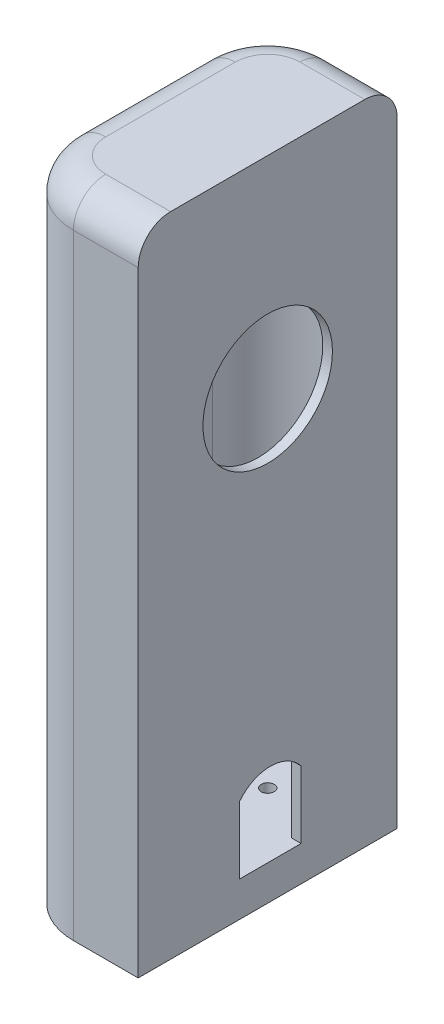
from build123d import *

# Parameters (mm, degrees)
BOSS_EXTRUDE1_DEPTH = 100
SKETCH2_R           = 10
CUT_EXTRUDE1_DEPTH  = 7.5
CUT_EXTRUDE2_DEPTH  = 4.75
SKETCH6_R           = 1
CUT_EXTRUDE3_DEPTH  = 6
SKETCH7_W           = 9.5
SKETCH7_H           = 7.367856256
CUT_EXTRUDE4_DEPTH  = 6
SKETCH8_W           = 9.5
SKETCH8_H           = 7.367856256
BOSS_EXTRUDE2_DEPTH = 12.5
SKETCH10_R          = 10
CUT_EXTRUDE5_DEPTH  = 68
FILLET1_R           = 5
CUT_EXTRUDE6_DEPTH  = 5
SKETCH13_W          = 9.5
SKETCH13_H          = 3
CUT_EXTRUDE7_DEPTH  = 5
CUT_EXTRUDE8_DEPTH  = 12.5
CUT_EXTRUDE9_DEPTH  = 5
SKETCH17_W          = 11
SKETCH17_H          = 9.5
CUT_EXTRUDE11_DEPTH = 90


with BuildPart() as part:
    # Sketch1 → Boss-Extrude1 (new body)
    with BuildSketch(Plane(origin=(0, 0, 0), x_dir=(1, 0, 0), z_dir=(0, 1, 0))):
        with BuildLine():
            Line((-4.0452326, 19.590813971), (5.9547674, 19.590813971))
            Line((5.9547674, 19.590813971), (5.9547674, -0.409186029))
            Line((5.9547674, -0.409186029), (5.9547674, -20.409186029))
            Line((5.9547674, -20.409186029), (-4.0452326, -20.409186029))
            ThreePointArc((-4.0452326, -20.409186029), (-11.116300412, -17.48025384), (-14.0452326, -10.409186029))
            Line((-14.0452326, -10.409186029), (-14.0452326, 9.590813971))
            ThreePointArc((-14.0452326, 9.590813971), (-11.116300412, 16.661881783), (-4.0452326, 19.590813971))
        make_face()
    extrude(amount=BOSS_EXTRUDE1_DEPTH)

    # Sketch2 → Cut-Extrude1 (cut)
    with BuildSketch(Plane(origin=(5.9547674, 0, 0), x_dir=(0, 0, -1), z_dir=(1, 0, 0))):
        with Locations((-0.409186029, 68.83)):
            Circle(SKETCH2_R)
    extrude(amount=-CUT_EXTRUDE1_DEPTH, mode=Mode.SUBTRACT)

    # Sketch4 → Cut-Extrude2 (cut, symmetric)
    with BuildSketch(Plane.XY):
        Polygon((-1.5452326, 89.777572113), (3.4547674, 89.777572113), (3.4547674, 12.777572113), (3.4547674, 5.409715857), (-15.452876316, 5.409715857), (-15.452876316, 12.777572113), (-1.5452326, 12.777572113), align=None)
    extrude(amount=CUT_EXTRUDE2_DEPTH, both=True, mode=Mode.SUBTRACT)

    # Sketch6 → Cut-Extrude3 (cut)
    with BuildSketch(Plane.XZ):
        with Locations((-4.0452326, -9.590813971)):
            Circle(SKETCH6_R)
        with Locations((-4.0452326, 10.409186029)):
            Circle(SKETCH6_R)
    extrude(amount=-CUT_EXTRUDE3_DEPTH, mode=Mode.SUBTRACT)

    # Sketch7 → Cut-Extrude4 (cut)
    with BuildSketch(Plane.ZY.offset(-3.4547674)):
        with Locations((0, 9.093643985)):
            Rectangle(SKETCH7_W, SKETCH7_H)
    extrude(amount=-CUT_EXTRUDE4_DEPTH, mode=Mode.SUBTRACT)

    # Sketch8 → Boss-Extrude2 (add)
    with BuildSketch(Plane.ZY.offset(14.0452326)):
        with Locations((0, 9.093643985)):
            Rectangle(SKETCH8_W, SKETCH8_H)
    extrude(amount=-BOSS_EXTRUDE2_DEPTH)

    # Sketch10 → Cut-Extrude5 (cut)
    with BuildSketch(Plane(origin=(5.9547674, 0, 0), x_dir=(0, 0, -1), z_dir=(1, 0, 0))):
        with Locations((-0.409186029, 68.83)):
            Circle(SKETCH10_R)
    extrude(amount=-CUT_EXTRUDE5_DEPTH, mode=Mode.SUBTRACT)

    # Fillet1
    fillet1_edges = [part.edges().sort_by_distance(p)[0] for p in [
        (-11.116300412, 100, -16.661881783),
        (-14.0452326, 100, 0.409186029),
        (-11.116300412, 100, 17.48025384),
        (0.9547674, 100, 20.409186029),
        (0.9547674, 100, -19.590813971),
    ]]
    fillet(fillet1_edges, radius=FILLET1_R)

    # Sketch11 → Cut-Extrude6 (cut)
    with BuildSketch(Plane(origin=(-1.5452326, 0, 0), x_dir=(0, 0, -1), z_dir=(1, 0, 0))):
        with BuildLine():
            Line((-4.75, 59.821263459), (-4.75, 5.409715857))
            Line((-4.75, 5.409715857), (4.75, 5.409715857))
            Line((4.75, 5.409715857), (4.75, 60.263623898))
            ThreePointArc((4.75, 60.263623898), (0.055952548, 58.840823552), (-4.75, 59.821263459))
        make_face()
    extrude(amount=-CUT_EXTRUDE6_DEPTH, mode=Mode.SUBTRACT)

    # Sketch13 → Cut-Extrude7 (cut)
    with BuildSketch(Plane(origin=(5.9547674, 0, 0), x_dir=(0, 0, -1), z_dir=(1, 0, 0))):
        with Locations((0, 14.277572113)):
            Rectangle(SKETCH13_W, SKETCH13_H)
    extrude(amount=-CUT_EXTRUDE7_DEPTH, mode=Mode.SUBTRACT)

    # Sketch14 → Cut-Extrude8 (cut)
    with BuildSketch(Plane(origin=(5.9547674, 0, 0), x_dir=(0, 0, -1), z_dir=(1, 0, 0))):
        with BuildLine():
            Line((4.75, 15.777572113), (-4.75, 15.777572113))
            ThreePointArc((-4.75, 15.777572113), (0, 18.113561026), (4.75, 15.777572113))
        make_face()
    extrude(amount=-CUT_EXTRUDE8_DEPTH, mode=Mode.SUBTRACT)

    # Sketch16 → Cut-Extrude9 (cut)
    with BuildSketch(Plane(origin=(-1.5452326, 0, 0), x_dir=(0, 0, -1), z_dir=(1, 0, 0))):
        with BuildLine():
            ThreePointArc((-4.75, 89.777572113), (0, 93.055148297), (4.75, 89.777572113))
            Line((4.75, 89.777572113), (-4.75, 89.777572113))
        make_face()
    extrude(amount=CUT_EXTRUDE9_DEPTH, mode=Mode.SUBTRACT)

    # Sketch17 → Cut-Extrude11 (cut)
    with BuildSketch(Plane(origin=(0, 5.409715857, 0), x_dir=(1, 0, 0), z_dir=(0, 1, 0))):
        with BuildLine():
            Line((4.4547674, 4.75), (4.4547674, 18.090813971))
            Line((4.4547674, 18.090813971), (-4.0452326, 18.090813971))
            ThreePointArc((-4.0452326, 18.090813971), (-10.05564024, 15.601221612), (-12.5452326, 9.590813971))
            Line((-12.5452326, 9.590813971), (-12.5452326, -10.409186029))
            ThreePointArc((-12.5452326, -10.409186029), (-10.05564024, -16.419593669), (-4.0452326, -18.909186029))
            Line((-4.0452326, -18.909186029), (4.4547674, -18.909186029))
            Line((4.4547674, -18.909186029), (4.4547674, -4.75))
            Line((4.4547674, -4.75), (-6.5452326, -4.75))
            Line((-6.5452326, -4.75), (-6.5452326, 4.75))
            Line((-6.5452326, 4.75), (4.4547674, 4.75))
        make_face()
        with Locations((-1.0452326, 0)):
            Rectangle(SKETCH17_W, SKETCH17_H)
    extrude(amount=CUT_EXTRUDE11_DEPTH, mode=Mode.SUBTRACT)


solid = part.part
